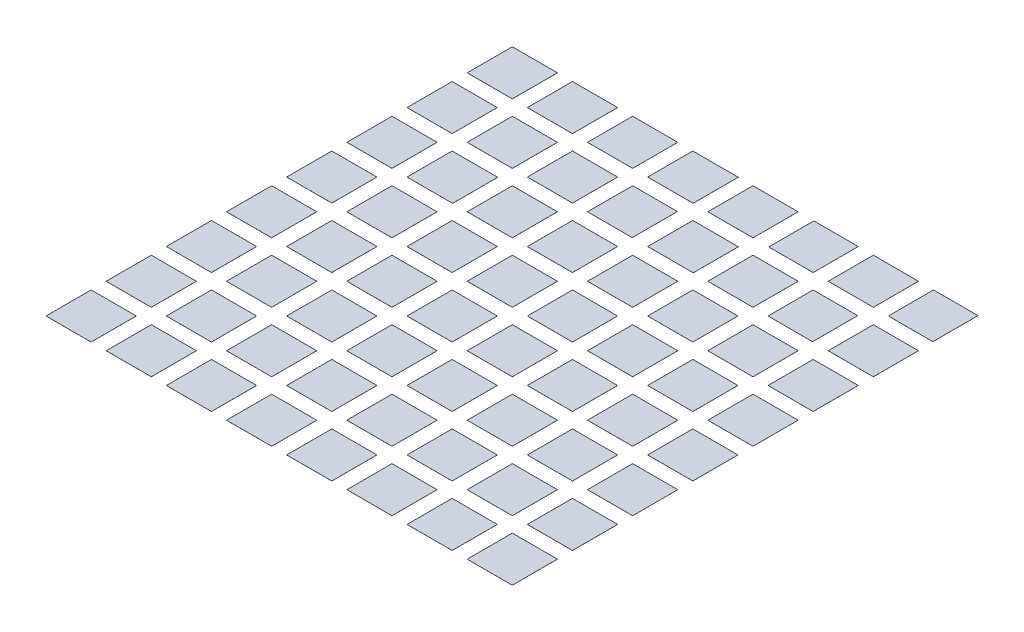
from build123d import *

# Parameters (mm, degrees)
BOSS_EXTRUDE1_DEPTH    = 0.001
BOSS_EXTRUDE1_2_DEPTH  = 0.001
BOSS_EXTRUDE1_3_DEPTH  = 0.001
BOSS_EXTRUDE1_4_DEPTH  = 0.001
BOSS_EXTRUDE1_5_DEPTH  = 0.001
BOSS_EXTRUDE1_6_DEPTH  = 0.001
BOSS_EXTRUDE1_7_DEPTH  = 0.001
BOSS_EXTRUDE1_8_DEPTH  = 0.001
BOSS_EXTRUDE1_9_DEPTH  = 0.001
BOSS_EXTRUDE1_10_DEPTH = 0.001
BOSS_EXTRUDE1_11_DEPTH = 0.001
BOSS_EXTRUDE1_12_DEPTH = 0.001
BOSS_EXTRUDE1_13_DEPTH = 0.001
BOSS_EXTRUDE1_14_DEPTH = 0.001
BOSS_EXTRUDE1_15_DEPTH = 0.001
BOSS_EXTRUDE1_16_DEPTH = 0.001
BOSS_EXTRUDE1_17_DEPTH = 0.001
BOSS_EXTRUDE1_18_DEPTH = 0.001
BOSS_EXTRUDE1_19_DEPTH = 0.001
BOSS_EXTRUDE1_20_DEPTH = 0.001
BOSS_EXTRUDE1_21_DEPTH = 0.001
BOSS_EXTRUDE1_22_DEPTH = 0.001
BOSS_EXTRUDE1_23_DEPTH = 0.001
BOSS_EXTRUDE1_24_DEPTH = 0.001
BOSS_EXTRUDE1_25_DEPTH = 0.001
BOSS_EXTRUDE1_26_DEPTH = 0.001
BOSS_EXTRUDE1_27_DEPTH = 0.001
BOSS_EXTRUDE1_28_DEPTH = 0.001
BOSS_EXTRUDE1_29_DEPTH = 0.001
BOSS_EXTRUDE1_30_DEPTH = 0.001
BOSS_EXTRUDE1_31_DEPTH = 0.001
BOSS_EXTRUDE1_32_DEPTH = 0.001
BOSS_EXTRUDE1_33_DEPTH = 0.001
BOSS_EXTRUDE1_34_DEPTH = 0.001
BOSS_EXTRUDE1_35_DEPTH = 0.001
BOSS_EXTRUDE1_36_DEPTH = 0.001
BOSS_EXTRUDE1_37_DEPTH = 0.001
BOSS_EXTRUDE1_38_DEPTH = 0.001
BOSS_EXTRUDE1_39_DEPTH = 0.001
BOSS_EXTRUDE1_40_DEPTH = 0.001
BOSS_EXTRUDE1_41_DEPTH = 0.001
BOSS_EXTRUDE1_42_DEPTH = 0.001
BOSS_EXTRUDE1_43_DEPTH = 0.001
BOSS_EXTRUDE1_44_DEPTH = 0.001
BOSS_EXTRUDE1_45_DEPTH = 0.001
BOSS_EXTRUDE1_46_DEPTH = 0.001
BOSS_EXTRUDE1_47_DEPTH = 0.001
BOSS_EXTRUDE1_48_DEPTH = 0.001
BOSS_EXTRUDE1_49_DEPTH = 0.001
BOSS_EXTRUDE1_50_DEPTH = 0.001
BOSS_EXTRUDE1_51_DEPTH = 0.001
BOSS_EXTRUDE1_52_DEPTH = 0.001
BOSS_EXTRUDE1_53_DEPTH = 0.001
BOSS_EXTRUDE1_54_DEPTH = 0.001
BOSS_EXTRUDE1_55_DEPTH = 0.001
BOSS_EXTRUDE1_56_DEPTH = 0.001
BOSS_EXTRUDE1_57_DEPTH = 0.001
BOSS_EXTRUDE1_58_DEPTH = 0.001
BOSS_EXTRUDE1_59_DEPTH = 0.001
BOSS_EXTRUDE1_60_DEPTH = 0.001
BOSS_EXTRUDE1_61_DEPTH = 0.001
BOSS_EXTRUDE1_62_DEPTH = 0.001
BOSS_EXTRUDE1_63_DEPTH = 0.001
BOSS_EXTRUDE1_64_DEPTH = 0.001


with BuildPart() as part:
    # 3DSketch1 → Boss-Extrude1 (new body)
    with BuildSketch(Plane(origin=(-26.056263002, 0, -0.503770895), x_dir=(0.7071067811865476, 0, 0.7071067811865475), z_dir=(0, -1, 0))):
        Polygon((0, 0), (1.060660172, 1.060660172), (2.121320344, 0), (1.060660172, -1.060660172), align=None)
    extrude(amount=-BOSS_EXTRUDE1_DEPTH)


with BuildPart() as body_2:
    # 3DSketch1 → Boss-Extrude1 2 (new body)
    with BuildSketch(Plane(origin=(-26.056263002, 0, -0.503770895), x_dir=(0.7071067811865476, 0, 0.7071067811865475), z_dir=(0, -1, 0))):
        Polygon((1.414213562, -1.414213562), (2.474873734, -0.353553391), (3.535533906, -1.414213562), (2.474873734, -2.474873734), align=None)
    extrude(amount=-BOSS_EXTRUDE1_2_DEPTH)


with BuildPart() as body_3:
    # 3DSketch1 → Boss-Extrude1 3 (new body)
    with BuildSketch(Plane(origin=(-26.056263002, 0, -0.503770895), x_dir=(0.7071067811865476, 0, 0.7071067811865475), z_dir=(0, -1, 0))):
        Polygon((2.828427125, -2.828427125), (3.889087297, -1.767766953), (4.949747468, -2.828427125), (3.889087297, -3.889087297), align=None)
    extrude(amount=-BOSS_EXTRUDE1_3_DEPTH)


with BuildPart() as body_4:
    # 3DSketch1 → Boss-Extrude1 4 (new body)
    with BuildSketch(Plane(origin=(-26.056263002, 0, -0.503770895), x_dir=(0.7071067811865476, 0, 0.7071067811865475), z_dir=(0, -1, 0))):
        Polygon((4.242640687, -4.242640687), (5.303300859, -3.181980515), (6.371740736, -4.250420393), (5.311080564, -5.311080564), align=None)
    extrude(amount=-BOSS_EXTRUDE1_4_DEPTH)


with BuildPart() as body_5:
    # 3DSketch1 → Boss-Extrude1 5 (new body)
    with BuildSketch(Plane(origin=(-26.056263002, 0, -0.503770895), x_dir=(0.7071067811865476, 0, 0.7071067811865475), z_dir=(0, -1, 0))):
        Polygon((5.656854249, -5.656854249), (6.717514421, -4.596194078), (7.778174593, -5.656854249), (6.717514421, -6.717514421), align=None)
    extrude(amount=-BOSS_EXTRUDE1_5_DEPTH)


with BuildPart() as body_6:
    # 3DSketch1 → Boss-Extrude1 6 (new body)
    with BuildSketch(Plane(origin=(-26.056263002, 0, -0.503770895), x_dir=(0.7071067811865476, 0, 0.7071067811865475), z_dir=(0, -1, 0))):
        Polygon((7.088549843, -7.088549843), (8.149210015, -6.027889671), (9.192388155, -7.071067812), (8.131727984, -8.131727984), align=None)
    extrude(amount=-BOSS_EXTRUDE1_6_DEPTH)


with BuildPart() as body_7:
    # 3DSketch1 → Boss-Extrude1 7 (new body)
    with BuildSketch(Plane(origin=(-26.056263002, 0, -0.503770895), x_dir=(0.7071067811865476, 0, 0.7071067811865475), z_dir=(0, -1, 0))):
        Polygon((8.485281374, -8.485281374), (9.545941546, -7.424621202), (10.606601718, -8.485281374), (9.545941546, -9.545941546), align=None)
    extrude(amount=-BOSS_EXTRUDE1_7_DEPTH)


with BuildPart() as body_8:
    # 3DSketch1 → Boss-Extrude1 8 (new body)
    with BuildSketch(Plane(origin=(-26.056263002, 0, -0.503770895), x_dir=(0.7071067811865476, 0, 0.7071067811865475), z_dir=(0, -1, 0))):
        Polygon((9.899494937, -9.899494937), (10.960155108, -8.838834765), (12.006292892, -9.884972549), (10.945632721, -10.945632721), align=None)
    extrude(amount=-BOSS_EXTRUDE1_8_DEPTH)


with BuildPart() as body_9:
    # 3DSketch1 → Boss-Extrude1 9 (new body)
    with BuildSketch(Plane(origin=(-26.056263002, 0, -0.503770895), x_dir=(0.7071067811865476, 0, 0.7071067811865475), z_dir=(0, -1, 0))):
        Polygon((1.414213562, 1.414213562), (2.474873734, 2.474873734), (3.535533906, 1.414213562), (2.474873734, 0.353553391), align=None)
    extrude(amount=-BOSS_EXTRUDE1_9_DEPTH)


with BuildPart() as body_10:
    # 3DSketch1 → Boss-Extrude1 10 (new body)
    with BuildSketch(Plane(origin=(-26.056263002, 0, -0.503770895), x_dir=(0.7071067811865476, 0, 0.7071067811865475), z_dir=(0, -1, 0))):
        Polygon((2.828427125, 0), (3.889087297, 1.060660172), (4.949747468, 0), (3.889087297, -1.060660172), align=None)
    extrude(amount=-BOSS_EXTRUDE1_10_DEPTH)


with BuildPart() as body_11:
    # 3DSketch1 → Boss-Extrude1 11 (new body)
    with BuildSketch(Plane(origin=(-26.056263002, 0, -0.503770895), x_dir=(0.7071067811865476, 0, 0.7071067811865475), z_dir=(0, -1, 0))):
        Polygon((4.242640687, -1.414213562), (5.303300859, -0.353553391), (6.363961031, -1.414213562), (5.303300859, -2.474873734), align=None)
    extrude(amount=-BOSS_EXTRUDE1_11_DEPTH)


with BuildPart() as body_12:
    # 3DSketch1 → Boss-Extrude1 12 (new body)
    with BuildSketch(Plane(origin=(-26.056263002, 0, -0.503770895), x_dir=(0.7071067811865476, 0, 0.7071067811865475), z_dir=(0, -1, 0))):
        Polygon((7.071067812, -4.242640687), (8.131727984, -3.181980515), (9.202587519, -4.252840051), (8.141927348, -5.313500223), align=None)
    extrude(amount=-BOSS_EXTRUDE1_12_DEPTH)


with BuildPart() as body_13:
    # 3DSketch1 → Boss-Extrude1 13 (new body)
    with BuildSketch(Plane(origin=(-26.056263002, 0, -0.503770895), x_dir=(0.7071067811865476, 0, 0.7071067811865475), z_dir=(0, -1, 0))):
        Polygon((8.485281374, -5.656854249), (9.545941546, -4.596194078), (10.606601718, -5.656854249), (9.545941546, -6.717514421), align=None)
    extrude(amount=-BOSS_EXTRUDE1_13_DEPTH)


with BuildPart() as body_14:
    # 3DSketch1 → Boss-Extrude1 14 (new body)
    with BuildSketch(Plane(origin=(-26.056263002, 0, -0.503770895), x_dir=(0.7071067811865476, 0, 0.7071067811865475), z_dir=(0, -1, 0))):
        Polygon((9.899494937, -7.071067812), (10.960155108, -6.01040764), (12.006801288, -7.05705382), (10.946141116, -8.117713992), align=None)
    extrude(amount=-BOSS_EXTRUDE1_14_DEPTH)


with BuildPart() as body_15:
    # 3DSketch1 → Boss-Extrude1 15 (new body)
    with BuildSketch(Plane(origin=(-26.056263002, 0, -0.503770895), x_dir=(0.7071067811865476, 0, 0.7071067811865475), z_dir=(0, -1, 0))):
        Polygon((11.313708499, -8.485281374), (12.374368671, -7.424621202), (13.435028843, -8.485281374), (12.374368671, -9.545941546), align=None)
    extrude(amount=-BOSS_EXTRUDE1_15_DEPTH)


with BuildPart() as body_16:
    # 3DSketch1 → Boss-Extrude1 16 (new body)
    with BuildSketch(Plane(origin=(-26.056263002, 0, -0.503770895), x_dir=(0.7071067811865476, 0, 0.7071067811865475), z_dir=(0, -1, 0))):
        Polygon((2.828427125, 2.828427125), (3.889087297, 3.889087297), (4.949747468, 2.828427125), (3.889087297, 1.767766953), align=None)
    extrude(amount=-BOSS_EXTRUDE1_16_DEPTH)


with BuildPart() as body_17:
    # 3DSketch1 → Boss-Extrude1 17 (new body)
    with BuildSketch(Plane(origin=(-26.056263002, 0, -0.503770895), x_dir=(0.7071067811865476, 0, 0.7071067811865475), z_dir=(0, -1, 0))):
        Polygon((4.242640687, 1.414213562), (5.303300859, 2.474873734), (6.374798394, 1.403376199), (5.314138222, 0.342716028), align=None)
    extrude(amount=-BOSS_EXTRUDE1_17_DEPTH)


with BuildPart() as body_18:
    # 3DSketch1 → Boss-Extrude1 18 (new body)
    with BuildSketch(Plane(origin=(-26.056263002, 0, -0.503770895), x_dir=(0.7071067811865476, 0, 0.7071067811865475), z_dir=(0, -1, 0))):
        Polygon((5.656854249, 0), (6.717514421, 1.060660172), (7.778174593, 0), (6.717514421, -1.060660172), align=None)
    extrude(amount=-BOSS_EXTRUDE1_18_DEPTH)


with BuildPart() as body_19:
    # 3DSketch1 → Boss-Extrude1 19 (new body)
    with BuildSketch(Plane(origin=(-26.056263002, 0, -0.503770895), x_dir=(0.7071067811865476, 0, 0.7071067811865475), z_dir=(0, -1, 0))):
        Polygon((7.071067812, -1.414213562), (8.131727984, -0.353553391), (9.192388155, -1.414213562), (8.131727984, -2.474873734), align=None)
    extrude(amount=-BOSS_EXTRUDE1_19_DEPTH)


with BuildPart() as body_20:
    # 3DSketch1 → Boss-Extrude1 20 (new body)
    with BuildSketch(Plane(origin=(-26.056263002, 0, -0.503770895), x_dir=(0.7071067811865476, 0, 0.7071067811865475), z_dir=(0, -1, 0))):
        Polygon((8.485281374, -2.828427125), (9.545941546, -1.767766953), (10.606601718, -2.828427125), (9.545941546, -3.889087297), align=None)
    extrude(amount=-BOSS_EXTRUDE1_20_DEPTH)


with BuildPart() as body_21:
    # 3DSketch1 → Boss-Extrude1 21 (new body)
    with BuildSketch(Plane(origin=(-26.056263002, 0, -0.503770895), x_dir=(0.7071067811865476, 0, 0.7071067811865475), z_dir=(0, -1, 0))):
        Polygon((9.899494937, -4.242640687), (10.960155108, -3.181980515), (12.02081528, -4.242640687), (10.960155108, -5.303300859), align=None)
    extrude(amount=-BOSS_EXTRUDE1_21_DEPTH)


with BuildPart() as body_22:
    # 3DSketch1 → Boss-Extrude1 22 (new body)
    with BuildSketch(Plane(origin=(-26.056263002, 0, -0.503770895), x_dir=(0.7071067811865476, 0, 0.7071067811865475), z_dir=(0, -1, 0))):
        Polygon((11.313708499, -5.656854249), (12.374368671, -4.596194078), (13.435028843, -5.656854249), (12.374368671, -6.717514421), align=None)
    extrude(amount=-BOSS_EXTRUDE1_22_DEPTH)


with BuildPart() as body_23:
    # 3DSketch1 → Boss-Extrude1 23 (new body)
    with BuildSketch(Plane(origin=(-26.056263002, 0, -0.503770895), x_dir=(0.7071067811865476, 0, 0.7071067811865475), z_dir=(0, -1, 0))):
        Polygon((12.727922061, -7.071067812), (13.788582233, -6.01040764), (14.849242405, -7.071067812), (13.788582233, -8.131727984), align=None)
    extrude(amount=-BOSS_EXTRUDE1_23_DEPTH)


with BuildPart() as body_24:
    # 3DSketch1 → Boss-Extrude1 24 (new body)
    with BuildSketch(Plane(origin=(-26.056263002, 0, -0.503770895), x_dir=(0.7071067811865476, 0, 0.7071067811865475), z_dir=(0, -1, 0))):
        Polygon((4.242640687, 4.242640687), (5.303300859, 5.303300859), (6.363961031, 4.242640687), (5.303300859, 3.181980515), align=None)
    extrude(amount=-BOSS_EXTRUDE1_24_DEPTH)


with BuildPart() as body_25:
    # 3DSketch1 → Boss-Extrude1 25 (new body)
    with BuildSketch(Plane(origin=(-26.056263002, 0, -0.503770895), x_dir=(0.7071067811865476, 0, 0.7071067811865475), z_dir=(0, -1, 0))):
        Polygon((5.656854249, 2.828427125), (6.717514421, 3.889087297), (7.778174593, 2.828427125), (6.717514421, 1.767766953), align=None)
    extrude(amount=-BOSS_EXTRUDE1_25_DEPTH)


with BuildPart() as body_26:
    # 3DSketch1 → Boss-Extrude1 26 (new body)
    with BuildSketch(Plane(origin=(-26.056263002, 0, -0.503770895), x_dir=(0.7071067811865476, 0, 0.7071067811865475), z_dir=(0, -1, 0))):
        Polygon((7.071067812, 1.414213562), (8.131727984, 2.474873734), (9.192388155, 1.414213562), (8.131727984, 0.353553391), align=None)
    extrude(amount=-BOSS_EXTRUDE1_26_DEPTH)


with BuildPart() as body_27:
    # 3DSketch1 → Boss-Extrude1 27 (new body)
    with BuildSketch(Plane(origin=(-26.056263002, 0, -0.503770895), x_dir=(0.7071067811865476, 0, 0.7071067811865475), z_dir=(0, -1, 0))):
        Polygon((8.485281374, 0), (9.545941546, 1.060660172), (10.606601718, 0), (9.545941546, -1.060660172), align=None)
    extrude(amount=-BOSS_EXTRUDE1_27_DEPTH)


with BuildPart() as body_28:
    # 3DSketch1 → Boss-Extrude1 28 (new body)
    with BuildSketch(Plane(origin=(-26.056263002, 0, -0.503770895), x_dir=(0.7071067811865476, 0, 0.7071067811865475), z_dir=(0, -1, 0))):
        Polygon((9.899494937, -1.414213562), (10.960155108, -0.353553391), (12.02081528, -1.414213562), (10.960155108, -2.474873734), align=None)
    extrude(amount=-BOSS_EXTRUDE1_28_DEPTH)


with BuildPart() as body_29:
    # 3DSketch1 → Boss-Extrude1 29 (new body)
    with BuildSketch(Plane(origin=(-26.056263002, 0, -0.503770895), x_dir=(0.7071067811865476, 0, 0.7071067811865475), z_dir=(0, -1, 0))):
        Polygon((11.313708499, -2.828427125), (12.374368671, -1.767766953), (13.435028843, -2.828427125), (12.374368671, -3.889087297), align=None)
    extrude(amount=-BOSS_EXTRUDE1_29_DEPTH)


with BuildPart() as body_30:
    # 3DSketch1 → Boss-Extrude1 30 (new body)
    with BuildSketch(Plane(origin=(-26.056263002, 0, -0.503770895), x_dir=(0.7071067811865476, 0, 0.7071067811865475), z_dir=(0, -1, 0))):
        Polygon((12.727922061, -4.242640687), (13.788582233, -3.181980515), (14.849242405, -4.242640687), (13.788582233, -5.303300859), align=None)
    extrude(amount=-BOSS_EXTRUDE1_30_DEPTH)


with BuildPart() as body_31:
    # 3DSketch1 → Boss-Extrude1 31 (new body)
    with BuildSketch(Plane(origin=(-26.056263002, 0, -0.503770895), x_dir=(0.7071067811865476, 0, 0.7071067811865475), z_dir=(0, -1, 0))):
        Polygon((14.142135624, -5.656854249), (15.202795796, -4.596194078), (16.263455967, -5.656854249), (15.202795796, -6.717514421), align=None)
    extrude(amount=-BOSS_EXTRUDE1_31_DEPTH)


with BuildPart() as body_32:
    # 3DSketch1 → Boss-Extrude1 32 (new body)
    with BuildSketch(Plane(origin=(-26.056263002, 0, -0.503770895), x_dir=(0.7071067811865476, 0, 0.7071067811865475), z_dir=(0, -1, 0))):
        Polygon((5.656854249, 5.656854249), (6.717514421, 6.717514421), (7.778174593, 5.656854249), (6.717514421, 4.596194078), align=None)
    extrude(amount=-BOSS_EXTRUDE1_32_DEPTH)


with BuildPart() as body_33:
    # 3DSketch1 → Boss-Extrude1 33 (new body)
    with BuildSketch(Plane(origin=(-26.056263002, 0, -0.503770895), x_dir=(0.7071067811865476, 0, 0.7071067811865475), z_dir=(0, -1, 0))):
        Polygon((7.071067812, 4.242640687), (8.131727984, 5.303300859), (9.192388155, 4.242640687), (8.131727984, 3.181980515), align=None)
    extrude(amount=-BOSS_EXTRUDE1_33_DEPTH)


with BuildPart() as body_34:
    # 3DSketch1 → Boss-Extrude1 34 (new body)
    with BuildSketch(Plane(origin=(-26.056263002, 0, -0.503770895), x_dir=(0.7071067811865476, 0, 0.7071067811865475), z_dir=(0, -1, 0))):
        Polygon((8.485281374, 2.828427125), (9.545941546, 3.889087297), (10.606601718, 2.828427125), (9.545941546, 1.767766953), align=None)
    extrude(amount=-BOSS_EXTRUDE1_34_DEPTH)


with BuildPart() as body_35:
    # 3DSketch1 → Boss-Extrude1 35 (new body)
    with BuildSketch(Plane(origin=(-26.056263002, 0, -0.503770895), x_dir=(0.7071067811865476, 0, 0.7071067811865475), z_dir=(0, -1, 0))):
        Polygon((9.899494937, 1.414213562), (10.960155108, 2.474873734), (12.02081528, 1.414213562), (10.960155108, 0.353553391), align=None)
    extrude(amount=-BOSS_EXTRUDE1_35_DEPTH)


with BuildPart() as body_36:
    # 3DSketch1 → Boss-Extrude1 36 (new body)
    with BuildSketch(Plane(origin=(-26.056263002, 0, -0.503770895), x_dir=(0.7071067811865476, 0, 0.7071067811865475), z_dir=(0, -1, 0))):
        Polygon((11.313708499, 0), (12.374368671, 1.060660172), (13.435028843, 0), (12.374368671, -1.060660172), align=None)
    extrude(amount=-BOSS_EXTRUDE1_36_DEPTH)


with BuildPart() as body_37:
    # 3DSketch1 → Boss-Extrude1 37 (new body)
    with BuildSketch(Plane(origin=(-26.056263002, 0, -0.503770895), x_dir=(0.7071067811865476, 0, 0.7071067811865475), z_dir=(0, -1, 0))):
        Polygon((12.727922061, -1.414213562), (13.788582233, -0.353553391), (14.849242405, -1.414213562), (13.788582233, -2.474873734), align=None)
    extrude(amount=-BOSS_EXTRUDE1_37_DEPTH)


with BuildPart() as body_38:
    # 3DSketch1 → Boss-Extrude1 38 (new body)
    with BuildSketch(Plane(origin=(-26.056263002, 0, -0.503770895), x_dir=(0.7071067811865476, 0, 0.7071067811865475), z_dir=(0, -1, 0))):
        Polygon((14.142135624, -2.828427125), (15.202795796, -1.767766953), (16.263455967, -2.828427125), (15.202795796, -3.889087297), align=None)
    extrude(amount=-BOSS_EXTRUDE1_38_DEPTH)


with BuildPart() as body_39:
    # 3DSketch1 → Boss-Extrude1 39 (new body)
    with BuildSketch(Plane(origin=(-26.056263002, 0, -0.503770895), x_dir=(0.7071067811865476, 0, 0.7071067811865475), z_dir=(0, -1, 0))):
        Polygon((15.556349186, -4.242640687), (16.617009358, -3.181980515), (17.67766953, -4.242640687), (16.617009358, -5.303300859), align=None)
    extrude(amount=-BOSS_EXTRUDE1_39_DEPTH)


with BuildPart() as body_40:
    # 3DSketch1 → Boss-Extrude1 40 (new body)
    with BuildSketch(Plane(origin=(-26.056263002, 0, -0.503770895), x_dir=(0.7071067811865476, 0, 0.7071067811865475), z_dir=(0, -1, 0))):
        Polygon((7.071067812, 7.071067812), (8.131727984, 8.131727984), (9.192388155, 7.071067812), (8.131727984, 6.01040764), align=None)
    extrude(amount=-BOSS_EXTRUDE1_40_DEPTH)


with BuildPart() as body_41:
    # 3DSketch1 → Boss-Extrude1 41 (new body)
    with BuildSketch(Plane(origin=(-26.056263002, 0, -0.503770895), x_dir=(0.7071067811865476, 0, 0.7071067811865475), z_dir=(0, -1, 0))):
        Polygon((8.485281374, 5.656854249), (9.545941546, 6.717514421), (10.606601718, 5.656854249), (9.545941546, 4.596194078), align=None)
    extrude(amount=-BOSS_EXTRUDE1_41_DEPTH)


with BuildPart() as body_42:
    # 3DSketch1 → Boss-Extrude1 42 (new body)
    with BuildSketch(Plane(origin=(-26.056263002, 0, -0.503770895), x_dir=(0.7071067811865476, 0, 0.7071067811865475), z_dir=(0, -1, 0))):
        Polygon((9.899494937, 4.242640687), (10.960155108, 5.303300859), (12.02081528, 4.242640687), (10.960155108, 3.181980515), align=None)
    extrude(amount=-BOSS_EXTRUDE1_42_DEPTH)


with BuildPart() as body_43:
    # 3DSketch1 → Boss-Extrude1 43 (new body)
    with BuildSketch(Plane(origin=(-26.056263002, 0, -0.503770895), x_dir=(0.7071067811865476, 0, 0.7071067811865475), z_dir=(0, -1, 0))):
        Polygon((11.313708499, 2.828427125), (12.374368671, 3.889087297), (13.435028843, 2.828427125), (12.374368671, 1.767766953), align=None)
    extrude(amount=-BOSS_EXTRUDE1_43_DEPTH)


with BuildPart() as body_44:
    # 3DSketch1 → Boss-Extrude1 44 (new body)
    with BuildSketch(Plane(origin=(-26.056263002, 0, -0.503770895), x_dir=(0.7071067811865476, 0, 0.7071067811865475), z_dir=(0, -1, 0))):
        Polygon((12.727922061, 1.414213562), (13.788582233, 2.474873734), (14.849242405, 1.414213562), (13.788582233, 0.353553391), align=None)
    extrude(amount=-BOSS_EXTRUDE1_44_DEPTH)


with BuildPart() as body_45:
    # 3DSketch1 → Boss-Extrude1 45 (new body)
    with BuildSketch(Plane(origin=(-26.056263002, 0, -0.503770895), x_dir=(0.7071067811865476, 0, 0.7071067811865475), z_dir=(0, -1, 0))):
        Polygon((14.142135624, 0), (15.202795796, 1.060660172), (16.263455967, 0), (15.202795796, -1.060660172), align=None)
    extrude(amount=-BOSS_EXTRUDE1_45_DEPTH)


with BuildPart() as body_46:
    # 3DSketch1 → Boss-Extrude1 46 (new body)
    with BuildSketch(Plane(origin=(-26.056263002, 0, -0.503770895), x_dir=(0.7071067811865476, 0, 0.7071067811865475), z_dir=(0, -1, 0))):
        Polygon((15.556349186, -1.414213562), (16.617009358, -0.353553391), (17.67766953, -1.414213562), (16.617009358, -2.474873734), align=None)
    extrude(amount=-BOSS_EXTRUDE1_46_DEPTH)


with BuildPart() as body_47:
    # 3DSketch1 → Boss-Extrude1 47 (new body)
    with BuildSketch(Plane(origin=(-26.056263002, 0, -0.503770895), x_dir=(0.7071067811865476, 0, 0.7071067811865475), z_dir=(0, -1, 0))):
        Polygon((8.485281374, 8.485281374), (9.545941546, 9.545941546), (10.606601718, 8.485281374), (9.545941546, 7.424621202), align=None)
    extrude(amount=-BOSS_EXTRUDE1_47_DEPTH)


with BuildPart() as body_48:
    # 3DSketch1 → Boss-Extrude1 48 (new body)
    with BuildSketch(Plane(origin=(-26.056263002, 0, -0.503770895), x_dir=(0.7071067811865476, 0, 0.7071067811865475), z_dir=(0, -1, 0))):
        Polygon((9.899494937, 7.071067812), (10.960155108, 8.131727984), (12.02081528, 7.071067812), (10.960155108, 6.01040764), align=None)
    extrude(amount=-BOSS_EXTRUDE1_48_DEPTH)


with BuildPart() as body_49:
    # 3DSketch1 → Boss-Extrude1 49 (new body)
    with BuildSketch(Plane(origin=(-26.056263002, 0, -0.503770895), x_dir=(0.7071067811865476, 0, 0.7071067811865475), z_dir=(0, -1, 0))):
        Polygon((11.313708499, 5.656854249), (12.374368671, 6.717514421), (13.435028843, 5.656854249), (12.374368671, 4.596194078), align=None)
    extrude(amount=-BOSS_EXTRUDE1_49_DEPTH)


with BuildPart() as body_50:
    # 3DSketch1 → Boss-Extrude1 50 (new body)
    with BuildSketch(Plane(origin=(-26.056263002, 0, -0.503770895), x_dir=(0.7071067811865476, 0, 0.7071067811865475), z_dir=(0, -1, 0))):
        Polygon((12.727922061, 4.242640687), (13.788582233, 5.303300859), (14.849242405, 4.242640687), (13.788582233, 3.181980515), align=None)
    extrude(amount=-BOSS_EXTRUDE1_50_DEPTH)


with BuildPart() as body_51:
    # 3DSketch1 → Boss-Extrude1 51 (new body)
    with BuildSketch(Plane(origin=(-26.056263002, 0, -0.503770895), x_dir=(0.7071067811865476, 0, 0.7071067811865475), z_dir=(0, -1, 0))):
        Polygon((14.142135624, 2.828427125), (15.202795796, 3.889087297), (16.263455967, 2.828427125), (15.202795796, 1.767766953), align=None)
    extrude(amount=-BOSS_EXTRUDE1_51_DEPTH)


with BuildPart() as body_52:
    # 3DSketch1 → Boss-Extrude1 52 (new body)
    with BuildSketch(Plane(origin=(-26.056263002, 0, -0.503770895), x_dir=(0.7071067811865476, 0, 0.7071067811865475), z_dir=(0, -1, 0))):
        Polygon((15.556349186, 1.414213562), (16.617009358, 2.474873734), (17.67766953, 1.414213562), (16.617009358, 0.353553391), align=None)
    extrude(amount=-BOSS_EXTRUDE1_52_DEPTH)


with BuildPart() as body_53:
    # 3DSketch1 → Boss-Extrude1 53 (new body)
    with BuildSketch(Plane(origin=(-26.056263002, 0, -0.503770895), x_dir=(0.7071067811865476, 0, 0.7071067811865475), z_dir=(0, -1, 0))):
        Polygon((16.970562748, 0), (18.03122292, 1.060660172), (19.091883092, 0), (18.03122292, -1.060660172), align=None)
    extrude(amount=-BOSS_EXTRUDE1_53_DEPTH)


with BuildPart() as body_54:
    # 3DSketch1 → Boss-Extrude1 54 (new body)
    with BuildSketch(Plane(origin=(-26.056263002, 0, -0.503770895), x_dir=(0.7071067811865476, 0, 0.7071067811865475), z_dir=(0, -1, 0))):
        Polygon((18.384776311, -1.414213562), (19.445436483, -0.353553391), (20.506096654, -1.414213562), (19.445436483, -2.474873734), align=None)
    extrude(amount=-BOSS_EXTRUDE1_54_DEPTH)


with BuildPart() as body_55:
    # 3DSketch1 → Boss-Extrude1 55 (new body)
    with BuildSketch(Plane(origin=(-26.056263002, 0, -0.503770895), x_dir=(0.7071067811865476, 0, 0.7071067811865475), z_dir=(0, -1, 0))):
        Polygon((9.899494937, 9.899494937), (10.960155108, 10.960155108), (12.02081528, 9.899494937), (10.960155108, 8.838834765), align=None)
    extrude(amount=-BOSS_EXTRUDE1_55_DEPTH)


with BuildPart() as body_56:
    # 3DSketch1 → Boss-Extrude1 56 (new body)
    with BuildSketch(Plane(origin=(-26.056263002, 0, -0.503770895), x_dir=(0.7071067811865476, 0, 0.7071067811865475), z_dir=(0, -1, 0))):
        Polygon((11.313708499, 8.485281374), (12.374368671, 9.545941546), (13.435028843, 8.485281374), (12.374368671, 7.424621202), align=None)
    extrude(amount=-BOSS_EXTRUDE1_56_DEPTH)


with BuildPart() as body_57:
    # 3DSketch1 → Boss-Extrude1 57 (new body)
    with BuildSketch(Plane(origin=(-26.056263002, 0, -0.503770895), x_dir=(0.7071067811865476, 0, 0.7071067811865475), z_dir=(0, -1, 0))):
        Polygon((12.727922061, 7.071067812), (13.788582233, 8.131727984), (14.849242405, 7.071067812), (13.788582233, 6.01040764), align=None)
    extrude(amount=-BOSS_EXTRUDE1_57_DEPTH)


with BuildPart() as body_58:
    # 3DSketch1 → Boss-Extrude1 58 (new body)
    with BuildSketch(Plane(origin=(-26.056263002, 0, -0.503770895), x_dir=(0.7071067811865476, 0, 0.7071067811865475), z_dir=(0, -1, 0))):
        Polygon((15.556349186, 4.242640687), (16.617009358, 5.303300859), (17.67766953, 4.242640687), (16.617009358, 3.181980515), align=None)
    extrude(amount=-BOSS_EXTRUDE1_58_DEPTH)


with BuildPart() as body_59:
    # 3DSketch1 → Boss-Extrude1 59 (new body)
    with BuildSketch(Plane(origin=(-26.056263002, 0, -0.503770895), x_dir=(0.7071067811865476, 0, 0.7071067811865475), z_dir=(0, -1, 0))):
        Polygon((16.970562748, 2.828427125), (18.03122292, 3.889087297), (19.091883092, 2.828427125), (18.03122292, 1.767766953), align=None)
    extrude(amount=-BOSS_EXTRUDE1_59_DEPTH)


with BuildPart() as body_60:
    # 3DSketch1 → Boss-Extrude1 60 (new body)
    with BuildSketch(Plane(origin=(-26.056263002, 0, -0.503770895), x_dir=(0.7071067811865476, 0, 0.7071067811865475), z_dir=(0, -1, 0))):
        Polygon((18.384776311, 1.414213562), (19.445436483, 2.474873734), (20.506096654, 1.414213562), (19.445436483, 0.353553391), align=None)
    extrude(amount=-BOSS_EXTRUDE1_60_DEPTH)


with BuildPart() as body_61:
    # 3DSketch1 → Boss-Extrude1 61 (new body)
    with BuildSketch(Plane(origin=(-26.056263002, 0, -0.503770895), x_dir=(0.7071067811865476, 0, 0.7071067811865475), z_dir=(0, -1, 0))):
        Polygon((5.656854249, -2.828427125), (6.717514421, -1.767766953), (7.768863485, -2.819116016), (6.708203313, -3.879776188), align=None)
    extrude(amount=-BOSS_EXTRUDE1_61_DEPTH)


with BuildPart() as body_62:
    # 3DSketch1 → Boss-Extrude1 62 (new body)
    with BuildSketch(Plane(origin=(-26.056263002, 0, -0.503770895), x_dir=(0.7071067811865476, 0, 0.7071067811865475), z_dir=(0, -1, 0))):
        Polygon((14.142135624, 5.656854249), (15.202795796, 6.717514421), (16.263455967, 5.656854249), (15.202795796, 4.596194078), align=None)
    extrude(amount=-BOSS_EXTRUDE1_62_DEPTH)


with BuildPart() as body_63:
    # 3DSketch1 → Boss-Extrude1 63 (new body)
    with BuildSketch(Plane(origin=(-26.056263002, 0, -0.503770895), x_dir=(0.7071067811865476, 0, 0.7071067811865475), z_dir=(0, -1, 0))):
        Polygon((19.798989873, 0), (20.859650045, 1.060660172), (21.920310217, 0), (20.859650045, -1.060660172), align=None)
    extrude(amount=-BOSS_EXTRUDE1_63_DEPTH)


with BuildPart() as body_64:
    # 3DSketch1 → Boss-Extrude1 64 (new body)
    with BuildSketch(Plane(origin=(-26.056263002, 0, -0.503770895), x_dir=(0.7071067811865476, 0, 0.7071067811865475), z_dir=(0, -1, 0))):
        Polygon((16.970562748, -2.828427125), (18.03122292, -1.767766953), (19.091883092, -2.828427125), (18.03122292, -3.889087297), align=None)
    extrude(amount=-BOSS_EXTRUDE1_64_DEPTH)


solid = Compound([part.part, body_2.part, body_3.part, body_4.part, body_5.part, body_6.part, body_7.part, body_8.part, body_9.part, body_10.part, body_11.part, body_12.part, body_13.part, body_14.part, body_15.part, body_16.part, body_17.part, body_18.part, body_19.part, body_20.part, body_21.part, body_22.part, body_23.part, body_24.part, body_25.part, body_26.part, body_27.part, body_28.part, body_29.part, body_30.part, body_31.part, body_32.part, body_33.part, body_34.part, body_35.part, body_36.part, body_37.part, body_38.part, body_39.part, body_40.part, body_41.part, body_42.part, body_43.part, body_44.part, body_45.part, body_46.part, body_47.part, body_48.part, body_49.part, body_50.part, body_51.part, body_52.part, body_53.part, body_54.part, body_55.part, body_56.part, body_57.part, body_58.part, body_59.part, body_60.part, body_61.part, body_62.part, body_63.part, body_64.part])
